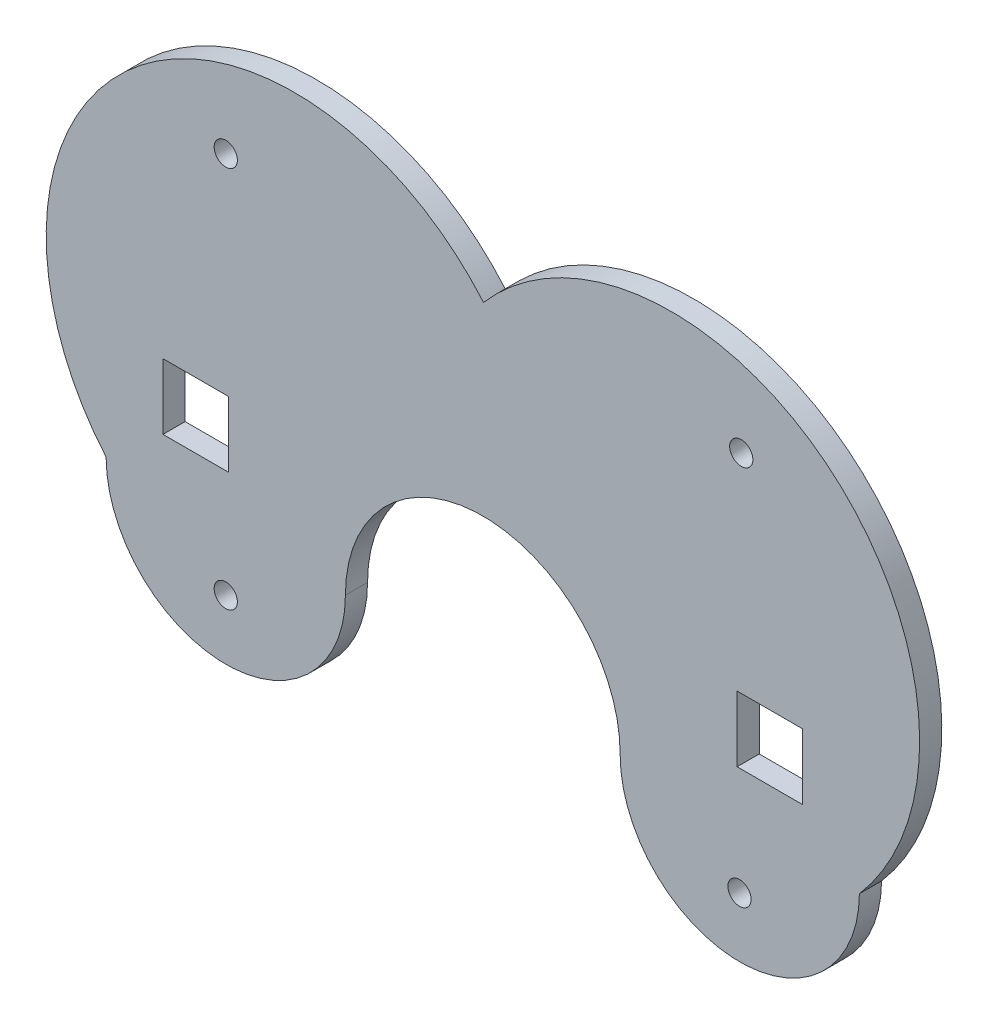
from build123d import *

# Parameters (mm, degrees)
BOSS_EXTRUDE1_DEPTH = 3.175
SKETCH2_R           = 1.6637
CUT_EXTRUDE1_DEPTH  = 3.175
SKETCH3_W           = 9.398
SKETCH3_H           = 9.398
CUT_EXTRUDE2_DEPTH  = 3.175


with BuildPart() as part:
    # Sketch1 → Boss-Extrude1 (new body)
    with BuildSketch(Plane.XY):
        with BuildLine():
            ThreePointArc((34.288648696, 17.145), (17.143648696, 0), (-0.001351304, 17.145))
            ThreePointArc((-0.001351304, 17.145), (3.871238611, 67.363724589), (54.080955836, 63.376050056))
            ThreePointArc((54.080955836, 63.376050056), (104.238720612, 67.087510011), (107.950180567, 16.929745235))
            ThreePointArc((107.950180567, 16.929745235), (90.72699247, -0.107108433), (73.66126725, 17.087472513))
            ThreePointArc((73.66126725, 17.087472513), (54.003763774, 36.831330291), (34.288648696, 17.145))
        make_face()
    extrude(amount=BOSS_EXTRUDE1_DEPTH)

    # Sketch2 → Cut-Extrude1 (cut)
    with BuildSketch(Plane.XY.offset(3.175)):
        with Locations((17.143648696, 8.5725)):
            Circle(SKETCH2_R)
        with Locations((90.766339889, 8.438225181)):
            Circle(SKETCH2_R)
        with Locations((17.143648696, 63.376050056)):
            Circle(SKETCH2_R)
        with Locations((91.017638263, 63.161224448)):
            Circle(SKETCH2_R)
    extrude(amount=-CUT_EXTRUDE1_DEPTH, mode=Mode.SUBTRACT)

    # Sketch3 → Cut-Extrude2 (cut)
    with BuildSketch(Plane.XY.offset(3.175)):
        with Locations((12.850394595, 28.73375)):
            Rectangle(SKETCH3_W, SKETCH3_H)
        with Locations((95.120347818, 28.620185079)):
            Rectangle(SKETCH3_W, SKETCH3_H)
    extrude(amount=-CUT_EXTRUDE2_DEPTH, mode=Mode.SUBTRACT)


solid = part.part
